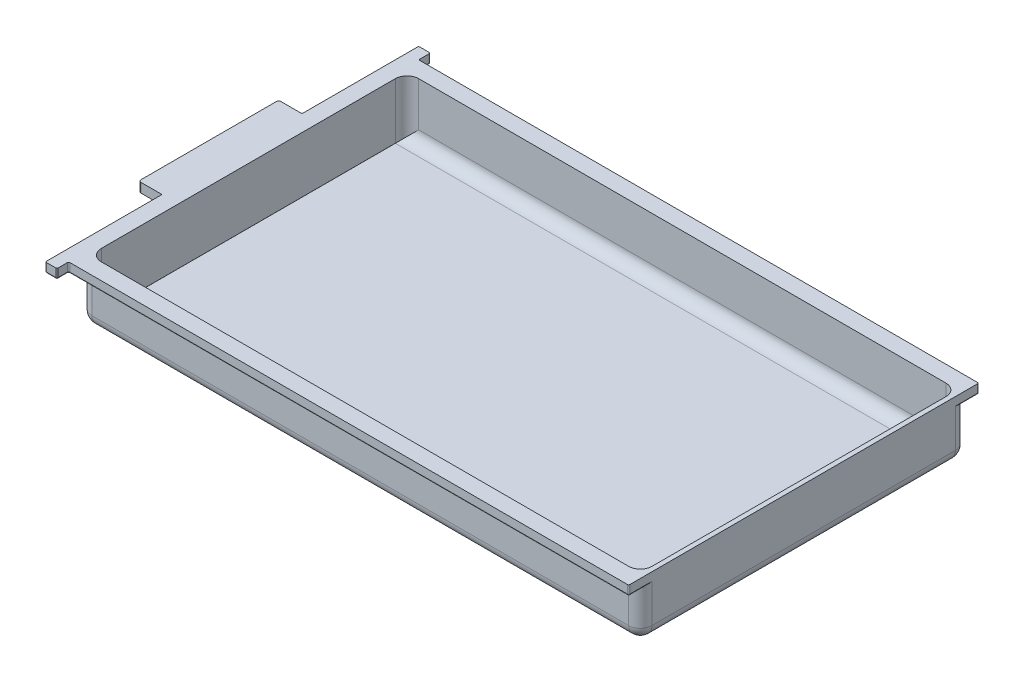
from build123d import *

# Parameters (mm, degrees)
SKETCH2_W           = 240
SKETCH2_H           = 140
BOSS_EXTRUDE1_DEPTH = 1
SKETCH3_W           = 240
SKETCH3_H           = 140
SKETCH3_W_2         = 236
SKETCH3_H_2         = 136
BOSS_EXTRUDE2_DEPTH = 20
SKETCH4_W           = 236
SKETCH4_H           = 136
BOSS_EXTRUDE3_DEPTH = 4
SKETCH6_W           = 11
SKETCH6_H           = 56
CUT_EXTRUDE2_DEPTH  = 3
FILLET1_R           = 5
FILLET2_R           = 5
FILLET3_R           = 0.5
FILLET4_R           = 1


with BuildPart() as part:
    # Sketch2 → Boss-Extrude1 (new body)
    with BuildSketch(Plane(origin=(0, 0, 0), x_dir=(1, 0, 0), z_dir=(0, 1, 0))):
        Rectangle(SKETCH2_W, SKETCH2_H)
    extrude(amount=BOSS_EXTRUDE1_DEPTH)

    # Sketch3 → Boss-Extrude2 (add)
    with BuildSketch(Plane(origin=(0, 1, 0), x_dir=(1, 0, 0), z_dir=(0, 1, 0))):
        Rectangle(SKETCH3_W, SKETCH3_H)
        Rectangle(SKETCH3_W_2, SKETCH3_H_2, mode=Mode.SUBTRACT)
    extrude(amount=BOSS_EXTRUDE2_DEPTH)

    # Sketch4 → Boss-Extrude3 (add)
    with BuildSketch(Plane(origin=(0, 21, 0), x_dir=(1, 0, 0), z_dir=(0, 1, 0))):
        Polygon((-125, 80), (-120, 80), (-120, 75), (120, 75), (120, -75), (-120, -75), (-120, -80), (-125, -80), (-125, -30), (-135, -30), (-135, 30), (-125, 30), align=None)
        Rectangle(SKETCH4_W, SKETCH4_H, mode=Mode.SUBTRACT)
    extrude(amount=BOSS_EXTRUDE3_DEPTH)

    # Sketch6 → Cut-Extrude2 (cut)
    with BuildSketch(Plane.XZ.offset(-21)):
        with Locations((-127.5, 0)):
            Rectangle(SKETCH6_W, SKETCH6_H)
    extrude(amount=-CUT_EXTRUDE2_DEPTH, mode=Mode.SUBTRACT)

    # Fillet1
    fillet1_edges = [part.edges().sort_by_distance(p)[0] for p in [
        (0, 1, 68),
        (118, 1, 0),
        (0, 1, -68),
        (-118, 13, 68),
        (118, 13, 68),
        (118, 13, -68),
        (-118, 13, -68),
        (-120, 0, 0),
    ]]
    fillet(fillet1_edges, radius=FILLET1_R)

    # Fillet2
    fillet2_edges = [part.edges().sort_by_distance(p)[0] for p in [
        (2.5, 0, 70),
        (-118.535533906, 1.464466094, 70),
        (-118.535533906, 1.464466094, -70),
        (2.5, 0, -70),
        (120, 0, 0),
        (120, 10.5, 70),
        (-120, 13, 70),
        (-120, 13, -70),
        (120, 10.5, -70),
    ]]
    fillet(fillet2_edges, radius=FILLET2_R)

    # Fillet3
    fillet3_edges = [part.edges().sort_by_distance(p)[0] for p in [
        (-125, 21, 55),
        (-122.5, 21, 80),
        (-125, 23, 80),
        (-120, 21, 77.5),
        (-120, 23, 80),
        (0, 21, 75),
        (-120, 23, 75),
        (120, 21, 67.5),
        (120, 21, -67.5),
        (120, 23, 75),
        (0, 21, -75),
        (120, 23, -75),
        (-120, 21, -77.5),
        (-120, 23, -75),
        (-122.5, 21, -80),
        (-120, 23, -80),
        (-125, 21, -55),
        (-125, 23, -80),
    ]]
    fillet(fillet3_edges, radius=FILLET3_R)

    # Fillet4
    fillet4_edges = [part.edges().sort_by_distance(p)[0] for p in [
        (-135, 23, -30),
        (-135, 23, 30),
        (-122, 24, 0),
        (-122, 22.5, 28),
        (-127.5, 24, -28),
        (-122, 22.5, -28),
        (-133, 24, 0),
        (-133, 22.5, -28),
        (-127.5, 24, 28),
        (-133, 22.5, 28),
    ]]
    fillet(fillet4_edges, radius=FILLET4_R)


solid = part.part
